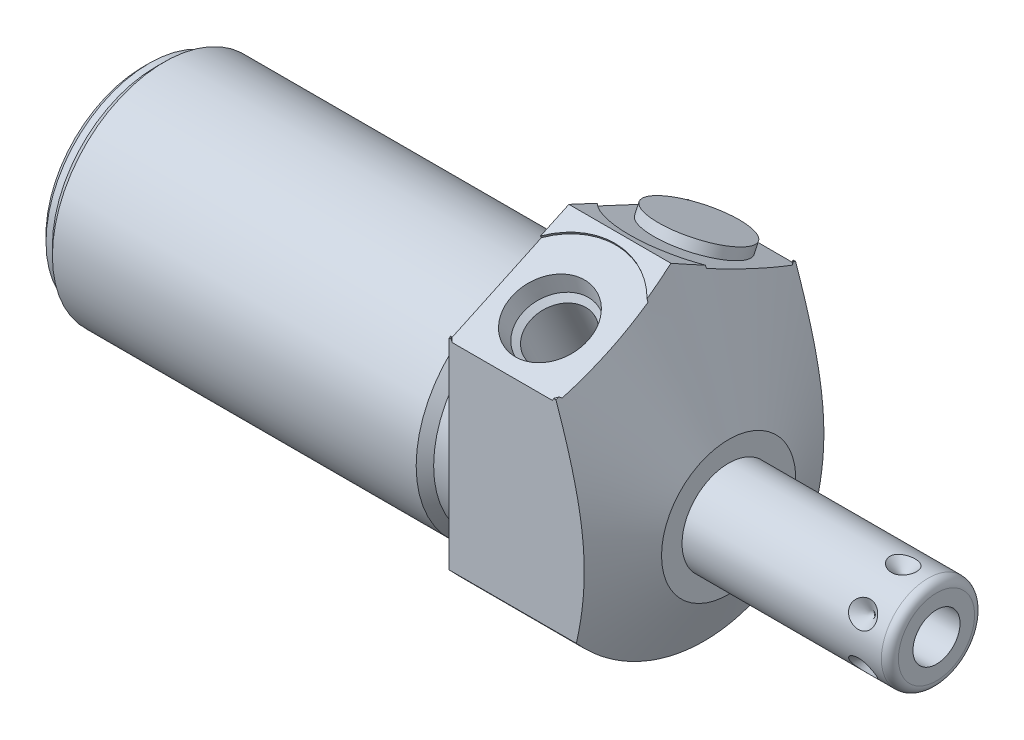
from build123d import *

# Parameters (mm, degrees)
SKETCH1_R           = 19.05
EXTRUDE1_DEPTH      = 19.05
EXTRUDE1_DEPTH_BACK = 50.8
CUT_EXTRUDE1_REACH  = 52.8
SKETCH2_R           = 19.05
SKETCH2_R_2         = 13.3604
CUT_EXTRUDE3_REACH  = 21.05
SKETCH19_R          = 8.6614
CUT_EXTRUDE4_DEPTH  = 0.254
SKETCH20_R          = 8.6614
CUT_EXTRUDE5_DEPTH  = 0.254
CHAMFER1_SIZE       = 0.762
SKETCH15_R          = 5.3086
EXTRUDE2_DEPTH      = 1.27
CIRPATTERN1_COUNT   = 6


with BuildPart() as part:
    # Sketch1 → Extrude1 (new body, two sides)
    with BuildSketch(Plane(origin=(0, 0, 0), x_dir=(0, 0, -1), z_dir=(1, 0, 0))) as extrude1_sk:
        Circle(SKETCH1_R)
    extrude(amount=EXTRUDE1_DEPTH)
    extrude(extrude1_sk.sketch, amount=-EXTRUDE1_DEPTH_BACK)

    # Sketch2 → Cut-Extrude1 (cut, up to next)
    with BuildSketch(Plane(origin=(0, 0, 0), x_dir=(0, 0, -1), z_dir=(1, 0, 0)), mode=Mode.PRIVATE) as cut_extrude1_sk1:
        Circle(SKETCH2_R)
        with Locations((0, -4.7498)):
            Circle(SKETCH2_R_2, mode=Mode.SUBTRACT)
    cut_extrude1_tool1 = extrude(cut_extrude1_sk1.sketch, amount=-CUT_EXTRUDE1_REACH, mode=Mode.PRIVATE) & part.part
    add(cut_extrude1_tool1.solids().sort_by_distance((0, 0, 18.511185))[0], mode=Mode.SUBTRACT)

    # Sketch4 → Cut-Extrude3 (cut, up to next)
    with BuildSketch(Plane.ZY, mode=Mode.PRIVATE) as cut_extrude3_sk1:
        with BuildLine():
            Line((14.2875, -12.600390619), (14.2875, 11.344778237))
            Line((14.2875, 11.344778237), (0, 18.007148903))
            Line((0, 18.007148903), (-14.2875, 11.344778237))
            Line((-14.2875, 11.344778237), (-14.2875, -12.600390619))
            ThreePointArc((-14.2875, -12.600390619), (0, 19.05), (14.2875, -12.600390619))
        make_face()
    cut_extrude3_tool1 = extrude(cut_extrude3_sk1.sketch, amount=-CUT_EXTRUDE3_REACH, mode=Mode.PRIVATE) & part.part
    add(cut_extrude3_tool1.solids().sort_by_distance((0, -0.627806, 14.782814))[0], mode=Mode.SUBTRACT)

    # Sketch6 → Cut-Revolve2 (revolve, cut)
    with BuildSketch(Plane.XY, mode=Mode.PRIVATE) as cut_revolve2_sk:
        Polygon((12.169188023, 18.007148903), (19.05, 3.2512), (19.05, 18.007148903), align=None)
    revolve(cut_revolve2_sk.sketch.rotate(Axis((1.987224567, -4.7498, 0), (1, 0, 0)), 270), axis=Axis((1.987224567, -4.7498, 0), (1, 0, 0)), mode=Mode.SUBTRACT)  # turned: the seam where the file's is

    # S2D0002 → Cut-Revolve3 (revolve, cut)
    with BuildSketch(Plane(origin=(6.35, 13.712414668, 8.609072086), x_dir=(0, 0.422618262, -0.906307787), z_dir=(1, 0, 0))):
        Polygon((0, 0), (4.5466, 0), (4.106586662, -2.0701), (3.4544, -2.722286662), (3.4544, -12.192), (0, -12.192), align=None)
    revolve(axis=Axis((6.35, 2.110224902, 3.198882147), (0, 0.906307787, 0.422618262)), mode=Mode.SUBTRACT)

    # Sketch19 → Cut-Extrude4 (cut)
    with BuildSketch(Plane(origin=(0, 14.790960552, 6.897138177), x_dir=(1, 0, 0), z_dir=(0, 0.906307787, 0.422618262))):
        with Locations((6.35, -2.00735222)):
            Circle(SKETCH19_R)
    extrude(amount=-CUT_EXTRUDE4_DEPTH, mode=Mode.SUBTRACT)

    # Sketch8 → Cut-Revolve4 (revolve, cut)
    with BuildSketch(Plane(origin=(6.35, 13.712414668, -8.609072086), x_dir=(0, -0.422618262, -0.906307787), z_dir=(1, 0, 0))):
        Polygon((0, 0), (4.5466, 0), (4.106586662, -2.0701), (3.4544, -2.722286662), (3.4544, -12.192), (0, -12.192), align=None)
    revolve(axis=Axis((6.35, 2.110224902, -3.198882147), (0, 0.906307787, -0.422618262)), mode=Mode.SUBTRACT)

    # Sketch20 → Cut-Extrude5 (cut)
    with BuildSketch(Plane(origin=(0, 14.790960552, -6.897138177), x_dir=(1, 0, 0), z_dir=(0, 0.906307787, -0.422618262))):
        with Locations((6.35, 2.00735222)):
            Circle(SKETCH20_R)
    extrude(amount=-CUT_EXTRUDE5_DEPTH, mode=Mode.SUBTRACT)

    # Sketch10 → Cut-Revolve6 (revolve, cut)
    with BuildSketch(Plane.XY, mode=Mode.PRIVATE) as cut_revolve6_sk:
        Polygon((0, 8.6106), (0, 7.5692), (-3.81, 7.5692), (-4.8514, 8.6106), align=None)
    revolve(cut_revolve6_sk.sketch.rotate(Axis((-5.09397, -4.7498, 0), (1, 0, 0)), 90), axis=Axis((-5.09397, -4.7498, 0), (1, 0, 0)), mode=Mode.SUBTRACT)  # turned: the seam where the file's is

    # Sketch12 → Cut-Revolve8 (revolve, cut)
    with BuildSketch(Plane.XY, mode=Mode.PRIVATE) as cut_revolve8_sk:
        Polygon((-50.8, 8.6106), (-50.8, 7.5692), (-49.276, 7.5692), (-48.2346, 8.6106), align=None)
    revolve(cut_revolve8_sk.sketch.rotate(Axis((-50.92827, -4.7498, 0), (1, 0, 0)), 90), axis=Axis((-50.92827, -4.7498, 0), (1, 0, 0)), mode=Mode.SUBTRACT)  # turned: the seam where the file's is

    # Chamfer1
    chamfer1_edges = [part.edges().sort_by_distance(p)[0] for p in [
        (-50.8, -4.7498, -12.319),
    ]]
    chamfer(chamfer1_edges, length=CHAMFER1_SIZE)

    # Sketch13 → Revolve1 (revolve)
    with BuildSketch(Plane(origin=(0, 0, 0), x_dir=(0, -1, 0), z_dir=(0, 0, 1)), mode=Mode.PRIVATE) as revolve1_sk:
        with BuildLine():
            Line((4.7498, 19.05), (4.7498, 43.8404))
            Line((4.7498, 43.8404), (9.29005, 43.8404))
            ThreePointArc((9.29005, 43.8404), (10.00847049, 43.54282049), (10.30605, 42.8244))
            Line((10.30605, 42.8244), (10.30605, 19.05))
            Line((10.30605, 19.05), (4.7498, 19.05))
        make_face()
    revolve(revolve1_sk.sketch.rotate(Axis((18.03654, -4.7498, 0), (1, 0, 0)), 270), axis=Axis((18.03654, -4.7498, 0), (1, 0, 0)))  # turned: the seam where the file's is

    # S2D0001 → Cut-Revolve9 (revolve, cut)
    with BuildSketch(Plane(origin=(39.3192, -7.5565, 0), x_dir=(0, -1, 0), z_dir=(0, 0, 1)), mode=Mode.PRIVATE) as cut_revolve9_sk:
        Polygon((0, 4.5212), (0, -5.6388), (-2.8067, -7.325235499), (-2.8067, 4.5212), align=None)
    revolve(cut_revolve9_sk.sketch.rotate(Axis((26.880442726, -4.7498, 0), (1, 0, 0)), 270), axis=Axis((26.880442726, -4.7498, 0), (1, 0, 0)), mode=Mode.SUBTRACT)  # turned: the seam where the file's is

    # Sketch15 → Extrude2 (add)
    with BuildSketch(Plane(origin=(19.05, 14.560758374, -6.789793138), x_dir=(0, -0.422618262, -0.906307787), z_dir=(0, -0.906307787, 0.422618262))):
        with Locations((2.00735222, -12.7)):
            Circle(SKETCH15_R)
    extrude(amount=-EXTRUDE2_DEPTH)

    # Sketch16 → Cut-Revolve10 (revolve, cut)
    with BuildSketch(Plane(origin=(35.3568, 0.80645, 0), x_dir=(-1, 0, 0), z_dir=(0, 0, -1)), mode=Mode.PRIVATE) as cut_revolve10_sk:
        Polygon((-4.5212, 0), (-2.9337, 0), (-4.5212, -1.5875), align=None)
    cut_revolve10 = revolve(cut_revolve10_sk.sketch.rotate(Axis((39.878, -2.672346388, 0), (0, 1, 0)), 90), axis=Axis((39.878, -2.672346388, 0), (0, 1, 0)), mode=Mode.SUBTRACT)  # turned: the seam where the file's is

    # CirPattern1: Cut-Revolve10 ×6 about axis
    cirpattern1_axis = Axis((18.03654, -4.7498, 0), (-1, 0, 0))
    for i in range(1, CIRPATTERN1_COUNT):
        add(cut_revolve10.rotate(cirpattern1_axis, i * 360 / CIRPATTERN1_COUNT), mode=Mode.SUBTRACT)


solid = part.part
